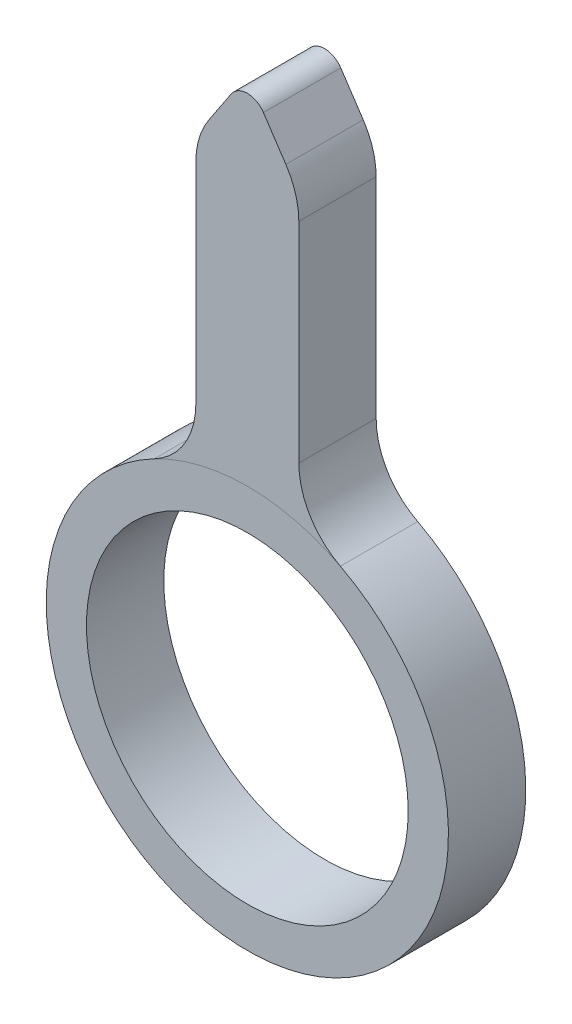
from build123d import *

# Parameters (mm, degrees)
SKETCH1_R           = 3.302
BOSS_EXTRUDE1_DEPTH = 1.5875
FILLET1_R           = 1.5875
FILLET2_R           = 0.396875
FILLET3_R           = 1.5875


with BuildPart() as part:
    # Sketch1 → Boss-Extrude1 (new body)
    with BuildSketch(Plane.XY):
        with BuildLine():
            Line((1.05664, 3.989958416), (1.05664, 9.8425))
            Line((1.05664, 9.8425), (0, 11.43))
            Line((0, 11.43), (-1.05664, 9.8425))
            Line((-1.05664, 9.8425), (-1.05664, 3.989958416))
            ThreePointArc((-1.05664, 3.989958416), (0, -4.1275), (1.05664, 3.989958416))
        make_face()
        Circle(SKETCH1_R, mode=Mode.SUBTRACT)
    extrude(amount=BOSS_EXTRUDE1_DEPTH)

    # Fillet1
    fillet1_edges = [part.edges().sort_by_distance(p)[0] for p in [
        (1.05664, 9.8425, 0.79375),
        (-1.05664, 9.8425, 0.79375),
    ]]
    fillet(fillet1_edges, radius=FILLET1_R)

    # Fillet2
    fillet2_edges = [part.edges().sort_by_distance(p)[0] for p in [
        (0, 11.43, 0.79375),
    ]]
    fillet(fillet2_edges, radius=FILLET2_R)

    # Fillet3
    fillet3_edges = [part.edges().sort_by_distance(p)[0] for p in [
        (1.05664, 3.989958416, 0.79375),
        (-1.05664, 3.989958416, 0.79375),
    ]]
    fillet(fillet3_edges, radius=FILLET3_R)


solid = part.part
